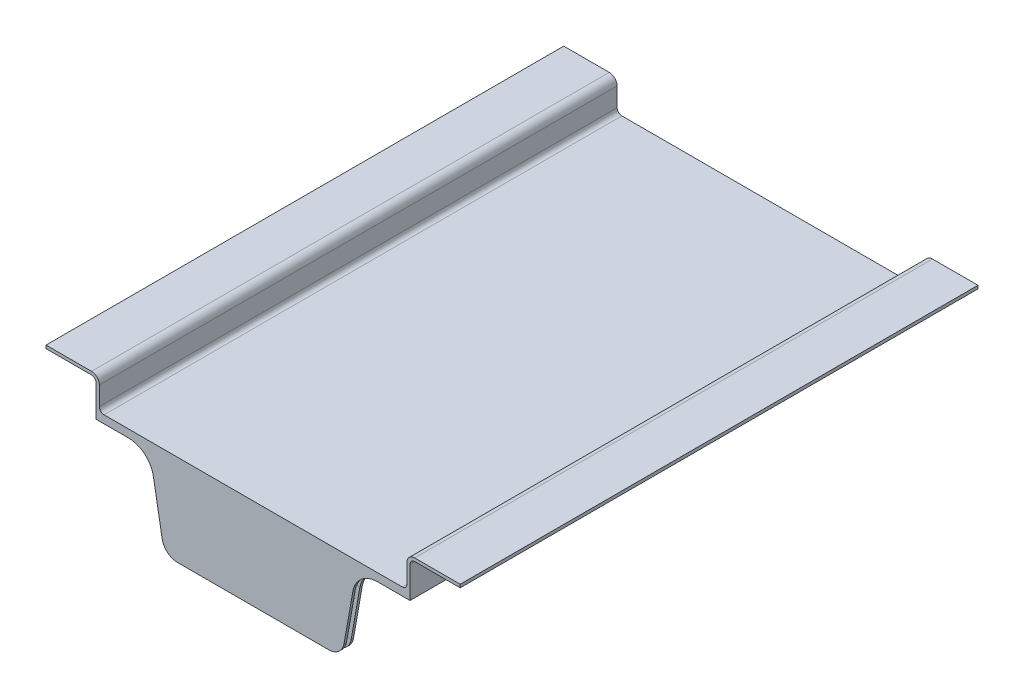
from build123d import *

# Parameters (mm, degrees)
BOSS_EXTRU_1_DEPTH       = 320
BOSS_EXTRU_1_DEPTH_BACK  = 10
ESQUISSE3_W              = 200
ESQUISSE3_H              = 6
BOSS_EXTRU_2_DEPTH       = 56.1
ESQUISSE41_W             = 200
ESQUISSE41_H             = 330
BOSS_EXTRU_9_DEPTH       = 3
ENL_V_MAT_EXTRU_22_DEPTH = 6
CONG_8_R                 = 10
CONG_9_R                 = 16
ESQUISSE48_W             = 3
ESQUISSE48_H             = 2.4


with BuildPart() as part:
    # Esquisse1 → Boss.-Extru.1 (new body, two sides)
    with BuildSketch(Plane.XY) as boss_extru_1_sk:
        with BuildLine():
            Line((-95, 2), (95, 2))
            ThreePointArc((95, 2), (97.121320344, 2.878679656), (98, 5))
            Line((98, 5), (98, 17))
            ThreePointArc((98, 17), (99.464466094, 20.535533906), (103, 22))
            Line((103, 22), (127, 22))
            Line((127, 22), (132, 22))
            Line((132, 22), (132, 20))
            Line((132, 20), (127, 20))
            Line((127, 20), (103, 20))
            ThreePointArc((103, 20), (100.878679656, 19.121320344), (100, 17))
            Line((100, 17), (100, 0))
            Line((100, 0), (-100, 0))
            Line((-100, 0), (-100, 17))
            ThreePointArc((-100, 17), (-100.878679656, 19.121320344), (-103, 20))
            Line((-103, 20), (-127, 20))
            Line((-127, 20), (-132, 20))
            Line((-132, 20), (-132, 22))
            Line((-132, 22), (-127, 22))
            Line((-127, 22), (-103, 22))
            ThreePointArc((-103, 22), (-99.464466094, 20.535533906), (-98, 17))
            Line((-98, 17), (-98, 5))
            ThreePointArc((-98, 5), (-97.121320344, 2.878679656), (-95, 2))
        make_face()
    extrude(amount=BOSS_EXTRU_1_DEPTH)
    extrude(boss_extru_1_sk.sketch, amount=-BOSS_EXTRU_1_DEPTH_BACK)

    # Esquisse3 → Boss.-Extru.2 (add)
    with BuildSketch(Plane(origin=(0, 0, 0), x_dir=(-1, 0, 0), z_dir=(0, -1, 0))):
        with Locations((0, -317)):
            Rectangle(ESQUISSE3_W, ESQUISSE3_H)
    extrude(amount=BOSS_EXTRU_2_DEPTH)

    # Esquisse41 → Boss.-Extru.9 (add)
    with BuildSketch(Plane.XZ):
        with Locations((0, 155)):
            Rectangle(ESQUISSE41_W, ESQUISSE41_H)
        with BuildLine():
            Line((84, 314), (-84, 314))
            ThreePointArc((-84, 314), (-91.071067812, 311.071067812), (-94, 304))
            Line((-94, 304), (-94, 6))
            ThreePointArc((-94, 6), (-91.071067812, -1.071067812), (-84, -4))
            Line((-84, -4), (84, -4))
            ThreePointArc((84, -4), (91.071067812, -1.071067812), (94, 6))
            Line((94, 6), (94, 304))
            ThreePointArc((94, 304), (91.071067812, 311.071067812), (84, 314))
        make_face(mode=Mode.SUBTRACT)
    extrude(amount=BOSS_EXTRU_9_DEPTH)

    # Esquisse24 → Enlèv. mat.-Extru.22 (cut)
    with BuildSketch(Plane.XY.offset(320)):
        Polygon((65.886245289, -3), (56.523282614, -56.1), (100, -56.1), (100, -3), align=None)
        Polygon((-65.886245289, -3), (-56.523282614, -56.1), (-100, -56.1), (-100, -3), align=None)
    extrude(amount=-ENL_V_MAT_EXTRU_22_DEPTH, mode=Mode.SUBTRACT)

    # Congé8
    cong_8_edges = [part.edges().sort_by_distance(p)[0] for p in [
        (56.523282614, -56.1, 317),
        (-56.523282614, -56.1, 317),
    ]]
    fillet(cong_8_edges, radius=CONG_8_R)

    # Congé9
    cong_9_edges = [part.edges().sort_by_distance(p)[0] for p in [
        (65.886245289, -3, 317),
        (-65.886245289, -3, 317),
    ]]
    fillet(cong_9_edges, radius=CONG_9_R)

    # Enlèvement de matière-Balayage2: sweep along a curve in space
    with BuildLine() as enl_vement_de_mati_re_balayage2_path:
        Line((0, -3, -7), (84, -3, -7))
        ThreePointArc((84, -3, -7), (93.192388155, -3, -3.192388155), (97, -3, 6))
        Line((97, -3, 6), (97, -3, 304))
        ThreePointArc((97, -3, 304), (93.192388155, -3, 313.192388155), (84, -3, 317))
        Line((84, -3, 317), (79.311839388, -3, 317))
        ThreePointArc((63.55491534, -16.221629157, 317), (69.027237633, -6.74328891, 317), (79.311839388, -3, 317))
        Line((57.980363832, -47.836481777, 317), (63.55491534, -16.221629157, 317))
        ThreePointArc((48.132286302, -56.1, 317), (54.560162399, -53.760444431, 317), (57.980363832, -47.836481777, 317))
        Line((0, -56.1, 317), (48.132286302, -56.1, 317))
    # Esquisse48 → Enlèvement de matière-Balayage2 (sweep, cut)
    with BuildSketch(Plane(origin=(0, 0, 0), x_dir=(0, 0, -1), z_dir=(1, 0, 0))):
        with Locations((7, -1.8)):
            Rectangle(ESQUISSE48_W, ESQUISSE48_H)
    sweep(path=enl_vement_de_mati_re_balayage2_path.line, mode=Mode.SUBTRACT)


solid = part.part
